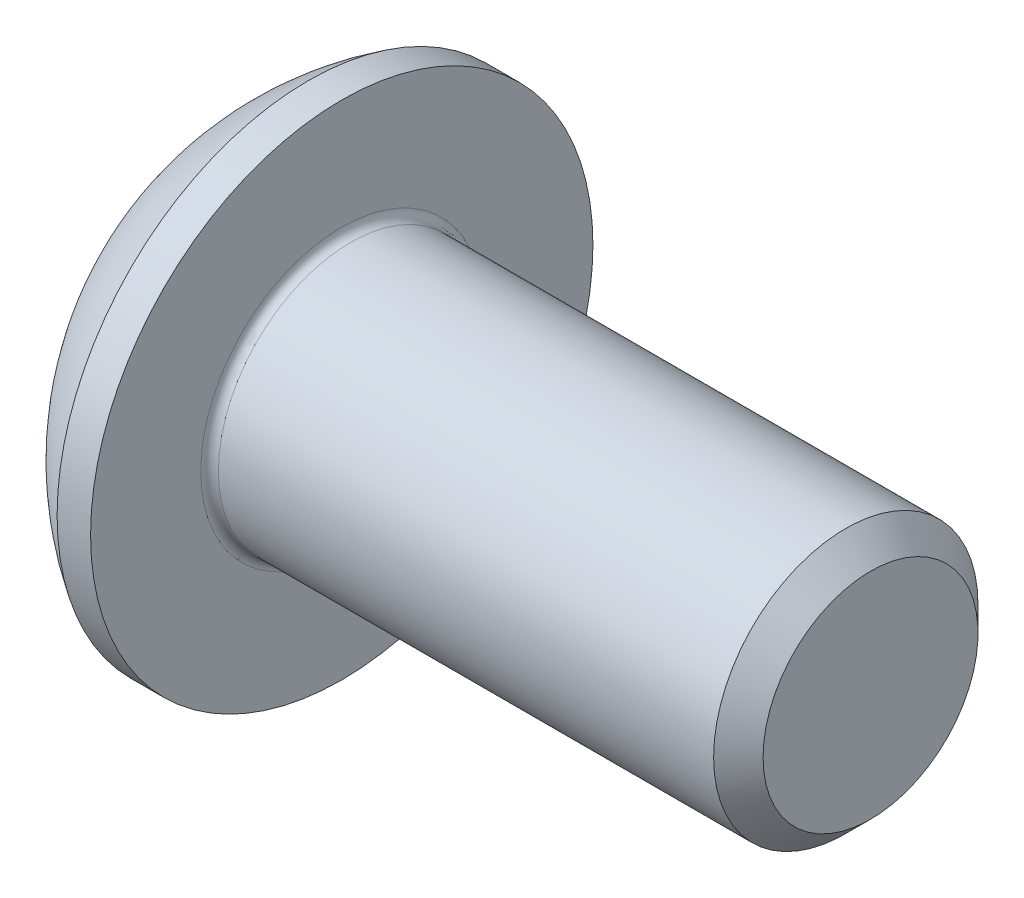
from build123d import *

# Parameters (mm, degrees)
FILLET1_R   = 0.1
HEX_2_DEPTH = 1.04


with BuildPart() as part:
    # BodySke → BaseBody (revolve)
    with BuildSketch(Plane.XY):
        with BuildLine():
            Line((7.65, 0), (7.65, 1.2195))
            Line((7.65, 1.2195), (7.3695, 1.5))
            Line((7.3695, 1.5), (1.65, 1.5))
            Line((1.65, 1.5), (1.65, 2.85))
            Line((1.65, 2.85), (1.27, 2.85))
            ThreePointArc((1.27, 2.85), (0.53140404, 2.229827628), (0, 1.425))
            Line((0, 1.425), (0, 0))
            Line((0, 0), (7.65, 0))
        make_face()
    revolve(axis=Axis((0, 0, 0), (1, 0, 0)))

    # Fillet1
    fillet1_edges = [part.edges().sort_by_distance(p)[0] for p in [
        (1.65, -1.5, 0),
    ]]
    fillet(fillet1_edges, radius=FILLET1_R)

    # Sketch2 → PreBroach (revolve, cut)
    with BuildSketch(Plane.XY):
        Polygon((0, 1), (1.04, 1), (1.617350269, 0), (0, 0), align=None)
    revolve(axis=Axis((0, 0, 0), (1, 0, 0)), mode=Mode.SUBTRACT)

    # Sketch3 → Hex 2 (cut)
    with BuildSketch(Plane(origin=(0, 0, 0), x_dir=(0, 0, -1), z_dir=(1, 0, 0))):
        Polygon((-1, -0.577350269), (-1, 0.577350269), (0, 1.154700538), (1, 0.577350269), (1, -0.577350269), (0, -1.154700538), align=None)
    extrude(amount=HEX_2_DEPTH, mode=Mode.SUBTRACT)


solid = part.part
